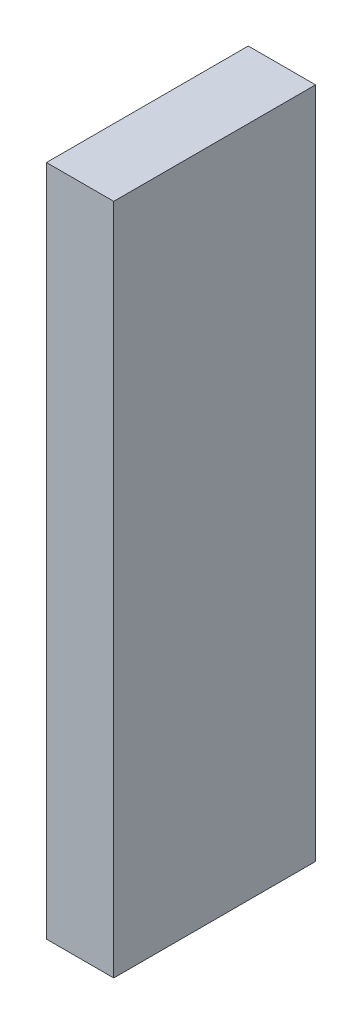
from build123d import *

# Parameters (mm, degrees)
SKETCH1_W           = 9.525
SKETCH1_H           = 31.75
BOSS_EXTRUDE1_DEPTH = 3.175


with BuildPart() as part:
    # Sketch1 → Boss-Extrude1 (new body)
    with BuildSketch(Plane(origin=(0, 0, 0), x_dir=(0, 0, -1), z_dir=(1, 0, 0))):
        Rectangle(SKETCH1_W, SKETCH1_H)
    extrude(amount=BOSS_EXTRUDE1_DEPTH)


solid = part.part
